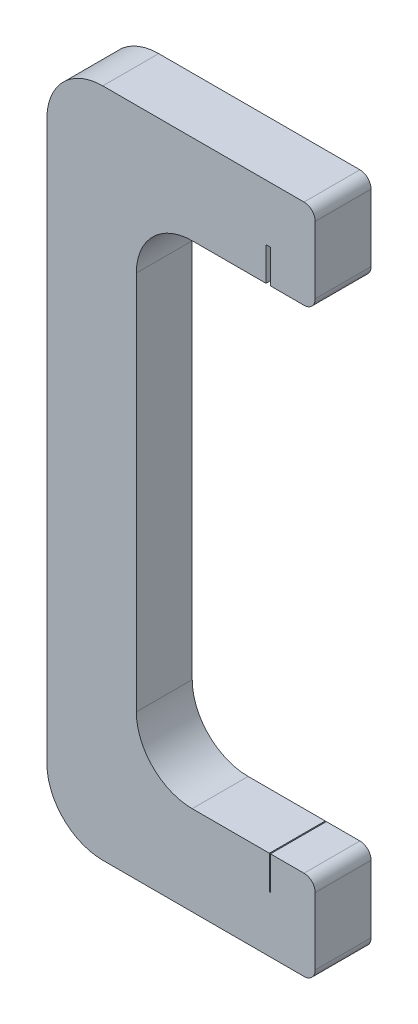
from build123d import *

# Parameters (mm, degrees)
BOSS_EXTRUDE1_DEPTH = 5
SKETCH3_W           = 0.1
SKETCH3_H           = 5
CUT_EXTRUDE1_DEPTH  = 3
SKETCH4_W           = 0.4
SKETCH4_H           = 5
CUT_EXTRUDE2_DEPTH  = 3


with BuildPart() as part:
    # Sketch1 → Boss-Extrude1 (new body)
    with BuildSketch(Plane.XY):
        with BuildLine():
            Line((0, 55), (0, 5))
            ThreePointArc((0, 5), (1.464466094, 1.464466094), (5, 0))
            Line((5, 0), (23, 0))
            ThreePointArc((23, 0), (23.707106781, 0.292893219), (24, 1))
            Line((24, 1), (24, 7))
            ThreePointArc((24, 7), (23.707106781, 7.707106781), (23, 8))
            Line((23, 8), (13, 8))
            ThreePointArc((13, 8), (9.464466094, 9.464466094), (8, 13))
            Line((8, 13), (8, 47))
            ThreePointArc((8, 47), (9.464466094, 50.535533906), (13, 52))
            Line((13, 52), (23, 52))
            ThreePointArc((23, 52), (23.707106781, 52.292893219), (24, 53))
            Line((24, 53), (24, 59))
            ThreePointArc((24, 59), (23.707106781, 59.707106781), (23, 60))
            Line((23, 60), (5, 60))
            ThreePointArc((5, 60), (1.464466094, 58.535533906), (0, 55))
        make_face()
    extrude(amount=BOSS_EXTRUDE1_DEPTH)

    # Sketch3 → Cut-Extrude1 (cut)
    with BuildSketch(Plane(origin=(0, 8, 0), x_dir=(1, 0, 0), z_dir=(0, 1, 0))):
        with Locations((19.95, -2.5)):
            Rectangle(SKETCH3_W, SKETCH3_H)
    extrude(amount=-CUT_EXTRUDE1_DEPTH, mode=Mode.SUBTRACT)

    # Sketch4 → Cut-Extrude2 (cut)
    with BuildSketch(Plane.XZ.offset(-52)):
        with Locations((19.8, 2.5)):
            Rectangle(SKETCH4_W, SKETCH4_H)
    extrude(amount=-CUT_EXTRUDE2_DEPTH, mode=Mode.SUBTRACT)


solid = part.part
